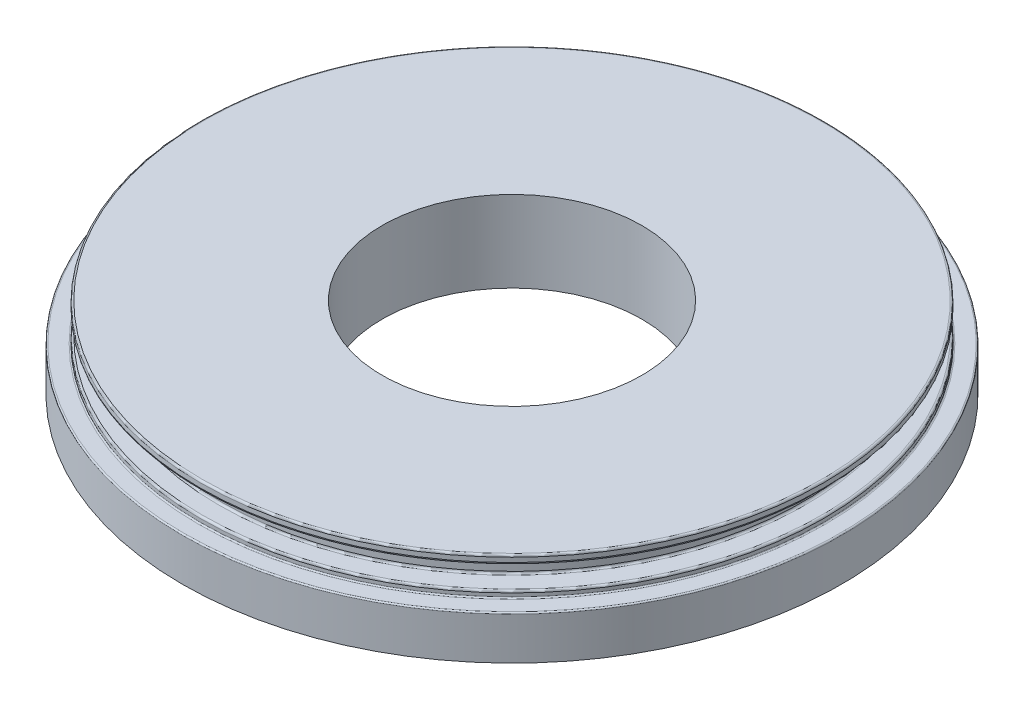
from build123d import *

# Parameters (mm, degrees)
FILLET2_R = 0.15
FILLET3_R = 0.15
FILLET4_R = 0.1
FILLET5_R = 0.15
FILLET6_R = 0.15


with BuildPart() as part:
    # Sketch1 → Revolve1 (revolve)
    with BuildSketch(Plane.XY):
        Polygon((9.93, 0), (9.93, 6.204285714), (23.845556077, 6.204285714), (23.845556077, 5.554285714), (22.25, 5.554285714), (22.25, 3.84), (23.845556077, 3.84), (23.845556077, 3.34), (25.2, 3.34), (25.2, 0), align=None)
    revolve(axis=Axis((0, 0, 0), (0, 1, 0)))

    # Fillet2
    fillet2_edges = [part.edges().sort_by_distance(p)[0] for p in [
        (-23.845556077, 6.204285714, 0),
    ]]
    fillet(fillet2_edges, radius=FILLET2_R)

    # Fillet3
    fillet3_edges = [part.edges().sort_by_distance(p)[0] for p in [
        (-23.845556077, 5.554285714, 0),
        (-23.845556077, 3.84, 0),
    ]]
    fillet(fillet3_edges, radius=FILLET3_R)

    # Fillet4
    fillet4_edges = [part.edges().sort_by_distance(p)[0] for p in [
        (-23.845556077, 3.34, 0),
        (-25.2, 3.34, 0),
    ]]
    fillet(fillet4_edges, radius=FILLET4_R)

    # Fillet5
    fillet5_edges = [part.edges().sort_by_distance(p)[0] for p in [
        (-22.25, 3.84, 0),
    ]]
    fillet(fillet5_edges, radius=FILLET5_R)

    # Fillet6
    fillet6_edges = [part.edges().sort_by_distance(p)[0] for p in [
        (-22.25, 5.554285714, 0),
    ]]
    fillet(fillet6_edges, radius=FILLET6_R)


solid = part.part
